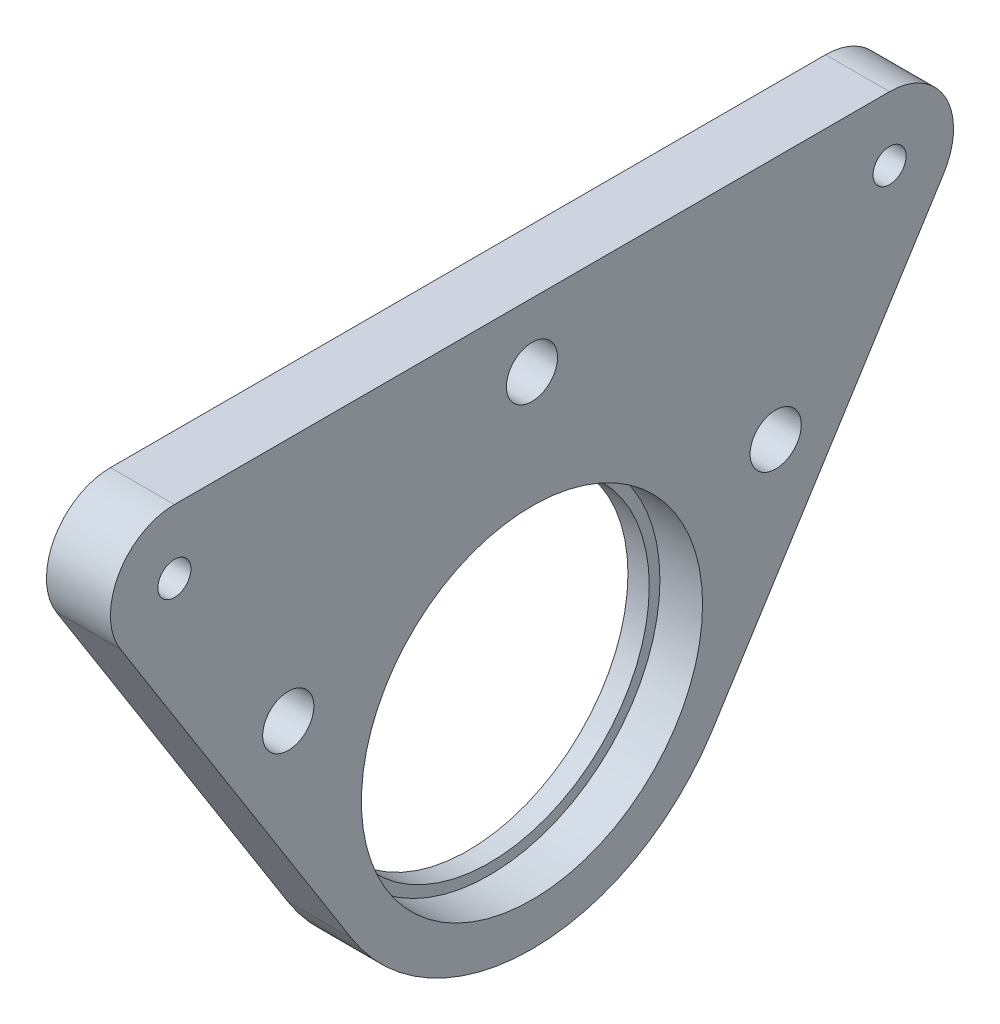
from build123d import *

# Parameters (mm, degrees)
SKETCH1_R           = 20
SKETCH1_R_2         = 15
BOSS_EXTRUDE1_DEPTH = 2
SKETCH2_R           = 20
SKETCH2_R_2         = 16
BOSS_EXTRUDE2_DEPTH = 4
SKETCH3_R           = 2
BOSS_EXTRUDE3_DEPTH = 6
SKETCH4_R           = 2.4
CUT_EXTRUDE1_DEPTH  = 6
SKETCH5_R           = 2
SKETCH5_R_2         = 1.55
BOSS_EXTRUDE4_DEPTH = 6


with BuildPart() as part:
    # Sketch1 → Boss-Extrude1 (new body)
    with BuildSketch(Plane(origin=(0, 0, 0), x_dir=(0, 0, -1), z_dir=(1, 0, 0))):
        Circle(SKETCH1_R)
        Circle(SKETCH1_R_2, mode=Mode.SUBTRACT)
    extrude(amount=BOSS_EXTRUDE1_DEPTH)

    # Sketch2 → Boss-Extrude2 (add)
    with BuildSketch(Plane(origin=(2, 0, 0), x_dir=(0, 0, -1), z_dir=(1, 0, 0))):
        Circle(SKETCH2_R)
        Circle(SKETCH2_R_2, mode=Mode.SUBTRACT)
    extrude(amount=BOSS_EXTRUDE2_DEPTH)

    # Sketch3 → Boss-Extrude3 (add)
    with BuildSketch(Plane(origin=(6, 0, 0), x_dir=(0, 0, -1), z_dir=(1, 0, 0))):
        with BuildLine():
            Line((-38.608830959, 23.677807584), (-16.909895057, -10.679674581))
            ThreePointArc((-16.909895057, -10.679674581), (0, 20), (16.909895057, -10.679674581))
            Line((16.909895057, -10.679674581), (38.608830959, 23.677807584))
            ThreePointArc((38.608830959, 23.677807584), (38.790546744, 29.777964933), (33.535862442, 32.881709959))
            Line((33.535862442, 32.881709959), (-33.535862442, 32.881709959))
            ThreePointArc((-33.535862442, 32.881709959), (-38.790546744, 29.777964933), (-38.608830959, 23.677807584))
        make_face()
        with Locations((-33.535862442, 26.881709959)):
            Circle(SKETCH3_R, mode=Mode.SUBTRACT)
        with Locations((33.535862442, 26.881709959)):
            Circle(SKETCH3_R, mode=Mode.SUBTRACT)
    extrude(amount=-BOSS_EXTRUDE3_DEPTH)

    # Sketch4 → Cut-Extrude1 (cut)
    with BuildSketch(Plane(origin=(6, 0, 0), x_dir=(0, 0, -1), z_dir=(1, 0, 0))):
        with Locations((-22.856187861, 9.971814902)):
            Circle(SKETCH4_R)
        with Locations((22.856187861, 9.971814902)):
            Circle(SKETCH4_R)
        with Locations((0, 26.881709959)):
            Circle(SKETCH4_R)
    extrude(amount=-CUT_EXTRUDE1_DEPTH, mode=Mode.SUBTRACT)

    # Sketch5 → Boss-Extrude4 (add)
    with BuildSketch(Plane(origin=(0, 0, 0), x_dir=(0, 0, -1), z_dir=(1, 0, 0))):
        with Locations((33.535862442, 26.881709959)):
            Circle(SKETCH5_R)
        with Locations((33.535862442, 26.881709959)):
            Circle(SKETCH5_R_2, mode=Mode.SUBTRACT)
        with Locations((-33.535862442, 26.881709959)):
            Circle(SKETCH5_R)
        with Locations((-33.535862442, 26.881709959)):
            Circle(SKETCH5_R_2, mode=Mode.SUBTRACT)
    extrude(amount=BOSS_EXTRUDE4_DEPTH)


solid = part.part
